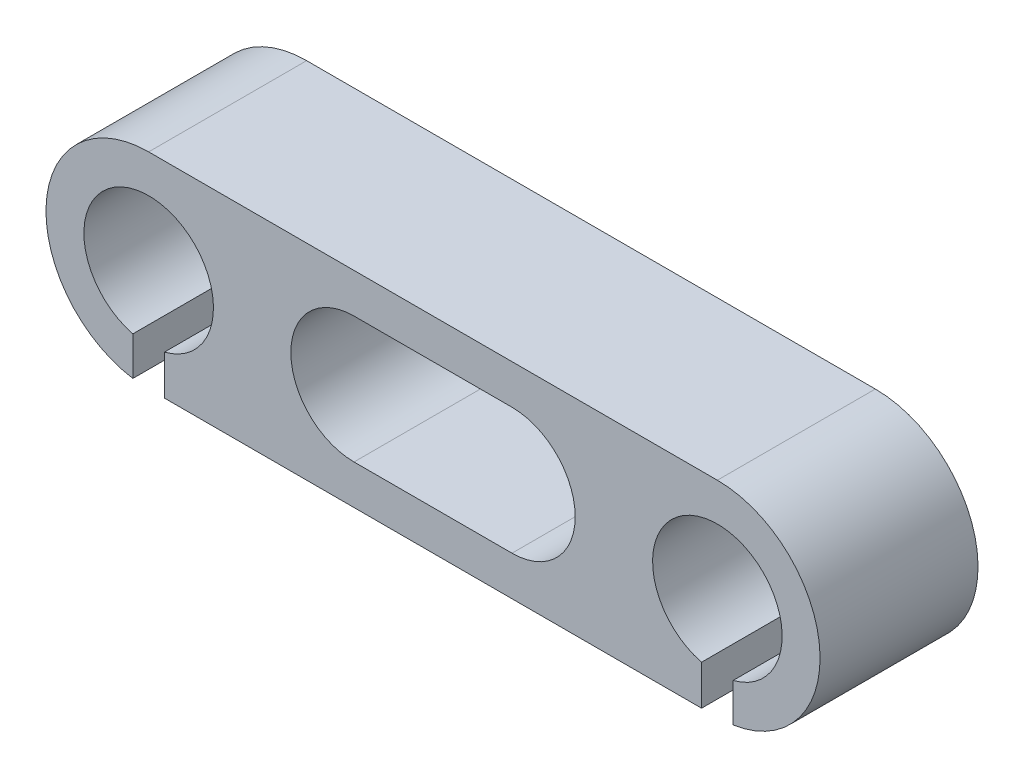
from build123d import *

# Parameters (mm, degrees)
SKETCH1_R               = 2.05
BOSS_EXTRUDE1_DEPTH     = 5
SKETCH2_W               = 1
SKETCH2_H               = 5
CUT_EXTRUDE_THIN1_DEPTH = 2


with BuildPart() as part:
    # Sketch1 → Boss-Extrude1 (new body)
    with BuildSketch(Plane.XY):
        with BuildLine():
            Line((0, 3.25), (18, 3.25))
            ThreePointArc((18, 3.25), (21.25, 0), (18, -3.25))
            Line((18, -3.25), (0, -3.25))
            ThreePointArc((0, -3.25), (-3.25, 0), (0, 3.25))
        make_face()
        Circle(SKETCH1_R, mode=Mode.SUBTRACT)
        with Locations((18, 0)):
            Circle(SKETCH1_R, mode=Mode.SUBTRACT)
        with BuildLine():
            Line((11.5, -2), (6.5, -2))
            ThreePointArc((6.5, -2), (4.5, 0), (6.5, 2))
            Line((6.5, 2), (11.5, 2))
            ThreePointArc((11.5, 2), (13.5, 0), (11.5, -2))
        make_face(mode=Mode.SUBTRACT)
    extrude(amount=BOSS_EXTRUDE1_DEPTH)

    # Sketch2 → Cut-Extrude-Thin1 (cut)
    with BuildSketch(Plane(origin=(0, -3.25, 0), x_dir=(-1, 0, 0), z_dir=(0, -1, 0))):
        with Locations((0, -2.5)):
            Rectangle(SKETCH2_W, SKETCH2_H)
        with Locations((-18, -2.5)):
            Rectangle(SKETCH2_W, SKETCH2_H)
    extrude(amount=-CUT_EXTRUDE_THIN1_DEPTH, mode=Mode.SUBTRACT)


solid = part.part
